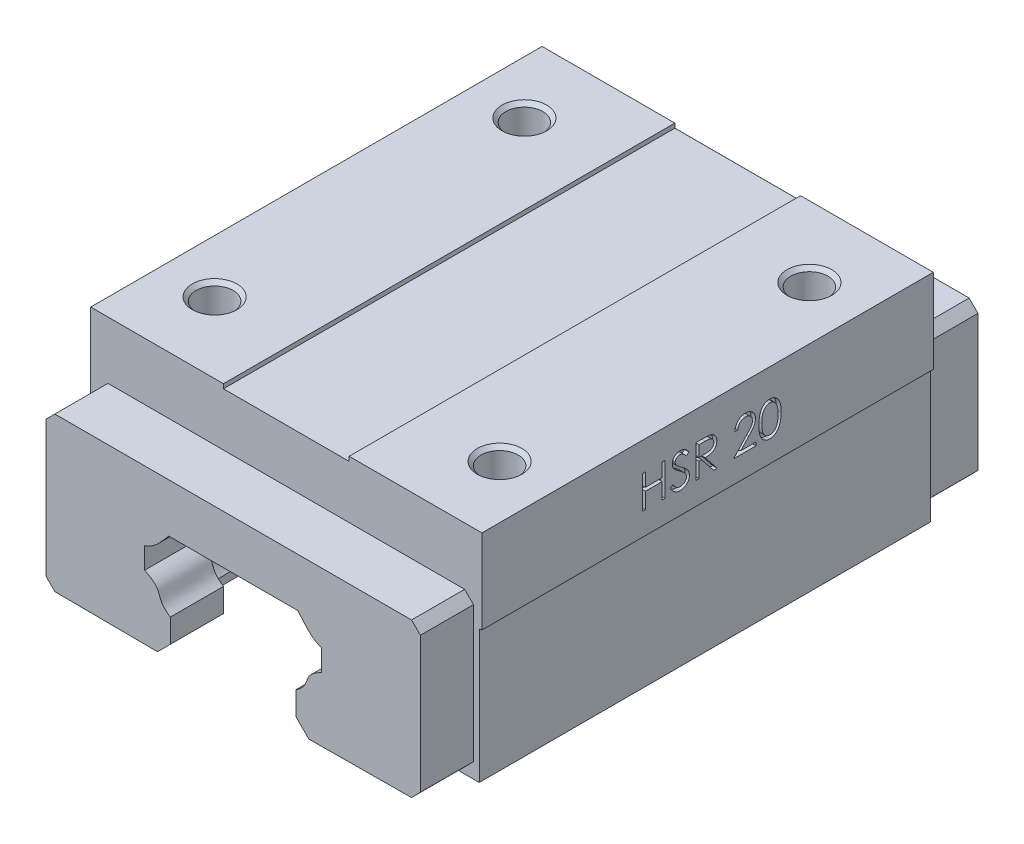
from build123d import *

# Parameters (mm, degrees)
BOSS_EXTRUDE1_DEPTH              = 51
BOSS_EXTRUDE3_DEPTH              = 6
CHAMFER1_SIZE                    = 1
CHAMFER1_EDGE_2_SIZE             = 1
CHAMFER1_EDGE_3_SIZE2            = 1.006844543
CHAMFER1_EDGE_3_SIZE             = 1
CHAMFER1_EDGE_4_SIZE2            = 1
CHAMFER1_EDGE_4_SIZE             = 1.006844543
CHAMFER1_OF_MIRROR4_SIZE         = 1
CHAMFER1_EDGE_2_OF_MIRROR4_SIZE  = 1
CHAMFER1_EDGE_3_OF_MIRROR4_SIZE2 = 1.006844543
CHAMFER1_EDGE_3_OF_MIRROR4_SIZE  = 1
CHAMFER1_EDGE_4_OF_MIRROR4_SIZE2 = 1
CHAMFER1_EDGE_4_OF_MIRROR4_SIZE  = 1.006844543
CUT_EXTRUDE1_DEPTH               = 0.5


with BuildPart() as part:
    # Sketch1 → Boss-Extrude1 (new body)
    with BuildSketch(Plane.XY):
        with BuildLine():
            Line((8.186769705, 11), (-8.186769705, 11))
            add(Edge.make_bspline(
                [(-8.186769705, 11), (-8.363836086, 10.799324769), (-8.709888403, 10.411068849), (-9.277449544, 9.75011771), (-9.7045178, 9.251154978), (-10.053828448, 8.908046415), (-10.269634561, 8.752888416), (-10.410763822, 8.68026119), (-10.489724529, 8.646859847), (-10.550742741, 8.625927759), (-10.57277649, 8.619058351), (-10.645173866, 8.597216578), (-10.745036898, 8.567019801), (-10.96378338, 8.500936701), (-11.38769033, 8.372834462), (-11.755697207, 8.261639185), (-12, 8.187818635)],
                knots=[-0.392908407, -0.392908407, -0.392908407, -0.392908407, -0.190329106, 0.012250195, 0.214829496, 0.417408798, 0.619988099, 0.721277749, 0.771922575, 0.8225674, 0.835228606, 0.847889813, 0.873212225, 0.923857051, 1.025146701, 1.227726002, 1.227726002, 1.227726002, 1.227726002], degree=3))
            Line((-12, 8.187818635), (-12, 2.939771986))
            add(Edge.make_bspline(
                [(-12, 2.939771986), (-11.765310399, 2.846514576), (-11.405654838, 2.703691145), (-11.012730745, 2.547344415), (-10.75009689, 2.443316846), (-10.629724696, 2.394119178), (-10.497141279, 2.327968435), (-10.336799963, 2.225917592), (-10.272656485, 2.169348301), (-10.226217691, 2.118184004)],
                knots=[-0.585104594, -0.585104594, -0.585104594, -0.585104594, -0.258530993, -0.095244192, -0.013600792, 0.068042608, 0.231329409, 0.39461621, 0.721189811, 0.721189811, 0.721189811, 0.721189811], degree=3))
            add(Edge.make_bspline(
                [(-10.226217691, 2.118184004), (-10.181586684, 1.988723576), (-10.098516815, 1.75729888), (-9.877516259, 1.266458818), (-9.562854794, 0.745877333), (-9.259202145, 0.381055923), (-9.1, 0.218184912)],
                knots=[0.146752228, 0.146752228, 0.146752228, 0.146752228, 0.298578938, 0.450405648, 0.602232359, 0.754059069, 0.754059069, 0.754059069, 0.754059069], degree=3))
            Line((-9.1, 0.218184912), (-9.1, -0.671572875))
            Line((-9.1, -0.671572875), (-12, -3.571572875))
            Line((-12, -3.571572875), (-21.8, -3.571572875))
            Line((-21.8, -3.571572875), (-21.8, 11.5))
            Line((-21.8, 11.5), (-22.1, 11.5))
            Line((-22.1, 11.5), (-22.1, 21))
            Line((-22.1, 21), (-7.1, 21))
            Line((-7.1, 21), (-7.1, 20.5))
            Line((-7.1, 20.5), (7.1, 20.5))
            Line((7.1, 20.5), (7.1, 21))
            Line((7.1, 21), (22.1, 21))
            Line((22.1, 21), (22.1, 11.5))
            Line((22.1, 11.5), (21.8, 11.5))
            Line((21.8, 11.5), (21.8, -3.571572875))
            Line((21.8, -3.571572875), (12, -3.571572875))
            Line((12, -3.571572875), (9.1, -0.671572875))
            Line((9.1, -0.671572875), (9.1, 0.218184912))
            add(Edge.make_bspline(
                [(9.1, 0.218184912), (9.259202145, 0.381055923), (9.562854794, 0.745877333), (9.877516259, 1.266458818), (10.098516815, 1.75729888), (10.181586684, 1.988723576), (10.226217691, 2.118184004)],
                knots=[0.146752228, 0.146752228, 0.146752228, 0.146752228, 0.298578938, 0.450405648, 0.602232359, 0.754059069, 0.754059069, 0.754059069, 0.754059069], degree=3))
            add(Edge.make_bspline(
                [(10.226217691, 2.118184004), (10.272656485, 2.169348301), (10.336799963, 2.225917592), (10.497141279, 2.327968435), (10.629724696, 2.394119178), (10.75009689, 2.443316846), (11.012730745, 2.547344415), (11.405654838, 2.703691145), (11.765310399, 2.846514576), (12, 2.939771986)],
                knots=[-0.585104594, -0.585104594, -0.585104594, -0.585104594, -0.258530993, -0.095244192, 0.068042608, 0.149686009, 0.231329409, 0.39461621, 0.721189811, 0.721189811, 0.721189811, 0.721189811], degree=3))
            Line((12, 2.939771986), (12, 8.187818635))
            add(Edge.make_bspline(
                [(12, 8.187818635), (11.755697207, 8.261639185), (11.38769033, 8.372834462), (10.96378338, 8.500936701), (10.745036898, 8.567019801), (10.645173866, 8.597216578), (10.57277649, 8.619058351), (10.550742741, 8.625927759), (10.489724529, 8.646859847), (10.410763822, 8.68026119), (10.269634561, 8.752888416), (10.053828448, 8.908046415), (9.7045178, 9.251154978), (9.277449544, 9.75011771), (8.709888403, 10.411068849), (8.363836086, 10.799324769), (8.186769705, 11)],
                knots=[-0.392908407, -0.392908407, -0.392908407, -0.392908407, -0.190329106, -0.089039455, -0.03839463, -0.013072217, -0.000411011, 0.012250195, 0.062895021, 0.113539846, 0.214829496, 0.417408798, 0.619988099, 0.8225674, 1.025146701, 1.227726002, 1.227726002, 1.227726002, 1.227726002], degree=3))
        make_face()
    extrude(amount=-BOSS_EXTRUDE1_DEPTH)

    # Sketch3 → M5 Tapped Hole1 (revolve, cut)
    with BuildSketch(Plane(origin=(-16.1, 21, -43), x_dir=(0, 0, 1), z_dir=(1, 0, 0))):
        Polygon((0, 0), (0, 9.2618073), (2.1, 8), (2.1, 0.425), (2.525, 0), align=None)
    m5_tapped_hole1 = revolve(axis=Axis((-16.1, 27.35, -43), (0, -1, 0)), mode=Mode.SUBTRACT)

    # Mirror1: M5 Tapped Hole1 across plane
    add(m5_tapped_hole1.mirror(Plane(origin=(0, 0, -25.5), x_dir=(1, 0, 0), z_dir=(0, 0, -1))), mode=Mode.SUBTRACT)

    # Mirror2: M5 Tapped Hole1 across plane
    add(m5_tapped_hole1.mirror(Plane.ZY), mode=Mode.SUBTRACT)

    # Mirror2 copy 1 sketch → Mirror2 copy 1 (revolve, cut)
    with BuildSketch(Plane(origin=(16.1, 21, -8), x_dir=(0, 0, -1), z_dir=(-1, 0, 0))):
        Polygon((0, 0), (0, 9.2618073), (2.1, 8), (2.1, 0.425), (2.525, 0), align=None)
    revolve(axis=Axis((16.1, 27.35, -8), (0, -1, 0)), mode=Mode.SUBTRACT)

    # Sketch5 → Boss-Extrude3 (add)
    with BuildSketch(Plane.XY):
        with BuildLine():
            Line((0, 14.507628115), (-21.14980175, 14.507628115))
            Line((-21.14980175, 14.507628115), (-21.14980175, -2.864633598))
            Line((-21.14980175, -2.864633598), (-8.55, -2.95))
            Line((-8.55, -2.95), (-7.1, -1.5))
            Line((-7.1, -1.5), (-7.1, 1.166788432))
            add(Edge.make_bspline(
                [(-10, 4.297156366), (-7.543055303, 3.07702891), (-9.018757763, 2.399897761), (-7.1, 1.166788432)],
                knots=[0, 0, 0, 0, 1, 1, 1, 1], degree=3))
            Line((-10, 4.297156366), (-10, 6.702843634))
            add(Edge.make_bspline(
                [(-10, 6.702843634), (-9.580341538, 6.835205115), (-9.158563098, 7.065013576), (-8.245096857, 7.844206232), (-7.926045594, 8.275331007), (-7.284232282, 9)],
                knots=[0, 0, 0, 0, 0.378200465, 0.478200465, 1, 1, 1, 1], degree=3))
            Line((-7.284232282, 9), (7.284232282, 9))
            add(Edge.make_bspline(
                [(10, 6.702843634), (9.580341538, 6.835205115), (9.158563098, 7.065013576), (8.245096857, 7.844206232), (7.926045594, 8.275331007), (7.284232282, 9)],
                knots=[0, 0, 0, 0, 0.378200465, 0.478200465, 1, 1, 1, 1], degree=3))
            Line((10, 6.702843634), (10, 4.297156366))
            add(Edge.make_bspline(
                [(10, 4.297156366), (7.543055303, 3.07702891), (9.018757763, 2.399897761), (7.1, 1.166788432)],
                knots=[0, 0, 0, 0, 1, 1, 1, 1], degree=3))
            Line((7.1, 1.166788432), (7.1, -1.5))
            Line((7.1, -1.5), (8.55, -2.95))
            Line((8.55, -2.95), (21.14980175, -2.864633598))
            Line((21.14980175, -2.864633598), (21.14980175, 14.507628115))
            Line((21.14980175, 14.507628115), (0, 14.507628115))
        make_face()
    boss_extrude3 = extrude(amount=BOSS_EXTRUDE3_DEPTH)

    # Chamfer1
    chamfer1_edges = [part.edges().sort_by_distance(p)[0] for p in [
        (21.14980175, 14.507628115, 3),
    ]]
    chamfer(chamfer1_edges, length=CHAMFER1_SIZE)

    # Chamfer1 edge 2
    chamfer1_edge_2_edges = [part.edges().sort_by_distance(p)[0] for p in [
        (-21.14980175, 14.507628115, 3),
    ]]
    chamfer(chamfer1_edge_2_edges, length=CHAMFER1_EDGE_2_SIZE)

    # Chamfer1 edge 3
    chamfer1_edge_3_edges = [part.edges().sort_by_distance(p)[0] for p in [
        (-21.14980175, -2.864633598, 3),
    ]]
    chamfer(chamfer1_edge_3_edges, length=CHAMFER1_EDGE_3_SIZE, length2=CHAMFER1_EDGE_3_SIZE2)

    # Chamfer1 edge 4
    chamfer1_edge_4_edges = [part.edges().sort_by_distance(p)[0] for p in [
        (21.14980175, -2.864633598, 3),
    ]]
    chamfer(chamfer1_edge_4_edges, length=CHAMFER1_EDGE_4_SIZE, length2=CHAMFER1_EDGE_4_SIZE2)

    # Mirror4: Boss-Extrude3 across plane
    add(boss_extrude3.mirror(Plane(origin=(0, 0, -25.5), x_dir=(1, 0, 0), z_dir=(0, 0, -1))))

    # Chamfer1 of Mirror4
    chamfer1_of_mirror4_edges = [part.edges().sort_by_distance(p)[0] for p in [
        (21.14980175, 14.507628115, -54),
    ]]
    chamfer(chamfer1_of_mirror4_edges, length=CHAMFER1_OF_MIRROR4_SIZE)

    # Chamfer1 edge 2 of Mirror4
    chamfer1_edge_2_of_mirror4_edges = [part.edges().sort_by_distance(p)[0] for p in [
        (-21.14980175, 14.507628115, -54),
    ]]
    chamfer(chamfer1_edge_2_of_mirror4_edges, length=CHAMFER1_EDGE_2_OF_MIRROR4_SIZE)

    # Chamfer1 edge 3 of Mirror4
    chamfer1_edge_3_of_mirror4_edges = [part.edges().sort_by_distance(p)[0] for p in [
        (-21.14980175, -2.864633598, -54),
    ]]
    chamfer(chamfer1_edge_3_of_mirror4_edges, length=CHAMFER1_EDGE_3_OF_MIRROR4_SIZE, length2=CHAMFER1_EDGE_3_OF_MIRROR4_SIZE2)

    # Chamfer1 edge 4 of Mirror4
    chamfer1_edge_4_of_mirror4_edges = [part.edges().sort_by_distance(p)[0] for p in [
        (21.14980175, -2.864633598, -54),
    ]]
    chamfer(chamfer1_edge_4_of_mirror4_edges, length=CHAMFER1_EDGE_4_OF_MIRROR4_SIZE, length2=CHAMFER1_EDGE_4_OF_MIRROR4_SIZE2)

    # Sketch6 → Cut-Extrude1 (cut)
    with BuildSketch(Plane(origin=(22.1, 0, 0), x_dir=(0, 0, -1), z_dir=(1, 0, 0))):
        Polygon((18.134408835, 17.740985443), (18.466834048, 17.740985443), (18.466834048, 16.221327324), (20.366406698, 16.221327324), (20.366406698, 17.740985443), (20.698831912, 17.740985443), (20.698831912, 14.036818777), (20.366406698, 14.036818777), (20.366406698, 15.841412794), (18.466834048, 15.841412794), (18.466834048, 14.036818777), (18.134408835, 14.036818777), align=None)
        with BuildLine():
            Line((21.268703706, 14.751384582), (21.581836385, 14.939115785))
            add(Edge.make_bspline(
                [(21.581836385, 14.939115785), (21.610959853, 14.890364311), (21.666759294, 14.796958368), (21.759841149, 14.670743609), (21.856290146, 14.56346866), (21.956820524, 14.475757583), (22.060818653, 14.406702511), (22.168963443, 14.35780515), (22.280890459, 14.327308242), (22.357062754, 14.323603984), (22.395090926, 14.321754674)],
                knots=[0, 0, 0, 0, 0.000170287, 0.000326263, 0.000469665, 0.000602223, 0.000725501, 0.000842734, 0.000957019, 0.001070958, 0.001070958, 0.001070958, 0.001070958], degree=3))
            add(Edge.make_bspline(
                [(22.395090926, 14.321754674), (22.427567853, 14.322659203), (22.491953438, 14.324452432), (22.586740145, 14.341682948), (22.678795886, 14.368154118), (22.766223361, 14.406064603), (22.84781622, 14.451931167), (22.919366639, 14.507330872), (22.981222109, 14.569355773), (23.031820088, 14.638552416), (23.070639792, 14.712971398), (23.100476398, 14.789357613), (23.117034101, 14.868911015), (23.119528332, 14.922473755), (23.12078704, 14.949504073)],
                knots=[0, 0, 0, 0, 9.7343e-05, 0.000192983, 0.000288081, 0.000384149, 0.00047821, 0.000568151, 0.000654726, 0.000740213, 0.000824192, 0.000905916, 0.00098552, 0.001066618, 0.001066618, 0.001066618, 0.001066618], degree=3))
            add(Edge.make_bspline(
                [(23.12078704, 14.949504073), (23.119226728, 14.980344806), (23.116054841, 15.043039508), (23.089245691, 15.135537475), (23.047071905, 15.227075444), (23.008164774, 15.283697617), (22.987965358, 15.313094151)],
                knots=[0, 0, 0, 0, 9.2372e-05, 0.000187779, 0.000286712, 0.000393535, 0.000393535, 0.000393535, 0.000393535], degree=3))
            add(Edge.make_bspline(
                [(22.987965358, 15.313094151), (22.971380625, 15.334310372), (22.936563052, 15.378851176), (22.876706351, 15.445150717), (22.80646888, 15.513538543), (22.728254285, 15.586626045), (22.639213432, 15.661013963), (22.542135146, 15.740249558), (22.434540895, 15.82131956), (22.359082261, 15.875688859), (22.320146849, 15.903742521)],
                knots=[0, 0, 0, 0, 8.0771e-05, 0.000169569, 0.000267687, 0.000374806, 0.000490623, 0.000615664, 0.000750713, 0.000894683, 0.000894683, 0.000894683, 0.000894683], degree=3))
            add(Edge.make_bspline(
                [(22.320146849, 15.903742521), (22.281174786, 15.93150111), (22.20666317, 15.984573417), (22.102461171, 16.063339118), (22.009280781, 16.135352213), (21.927536155, 16.201290626), (21.857263248, 16.261163299), (21.797908305, 16.314395285), (21.750983332, 16.36242622), (21.724889509, 16.393584974), (21.713174026, 16.407574486)],
                knots=[0, 0, 0, 0, 0.000143534, 0.000274427, 0.00039183, 0.000496823, 0.00058946, 0.000668773, 0.000735941, 0.00079067, 0.00079067, 0.00079067, 0.00079067], degree=3))
            add(Edge.make_bspline(
                [(21.713174026, 16.407574486), (21.696798915, 16.42937725), (21.664595063, 16.472255311), (21.622086041, 16.539274119), (21.585955427, 16.607878742), (21.557631959, 16.678253532), (21.533781127, 16.749410498), (21.517738984, 16.822278066), (21.507693922, 16.896529271), (21.506665236, 16.946496892), (21.506150288, 16.971510116)],
                knots=[0, 0, 0, 0, 8.1777e-05, 0.000160826, 0.000237825, 0.000314026, 0.000388176, 0.000462703, 0.00053753, 0.000612533, 0.000612533, 0.000612533, 0.000612533], degree=3))
            add(Edge.make_bspline(
                [(21.506150288, 16.971510116), (21.507531634, 17.010699961), (21.510264801, 17.088241995), (21.533379348, 17.201516291), (21.569863161, 17.309663582), (21.62097525, 17.411613185), (21.686864282, 17.504710515), (21.763112939, 17.590026456), (21.853930095, 17.661748205), (21.953574954, 17.7244143), (22.062642948, 17.773463738), (22.176933321, 17.810464108), (22.296627722, 17.831428906), (22.377699373, 17.834437499), (22.418835584, 17.835964076)],
                knots=[0, 0, 0, 0, 0.000117474, 0.000232437, 0.000345304, 0.000459127, 0.000573166, 0.00068662, 0.000801115, 0.000919096, 0.001038969, 0.001158885, 0.001278682, 0.00140208, 0.00140208, 0.00140208, 0.00140208], degree=3))
            add(Edge.make_bspline(
                [(22.418835584, 17.835964076), (22.46248559, 17.834458542), (22.549291521, 17.831464516), (22.676978607, 17.805432129), (22.799915366, 17.762357251), (22.898809488, 17.713474255), (22.976208327, 17.66465184), (23.035234469, 17.620180859), (23.095048771, 17.568983869), (23.156133712, 17.5109245), (23.217454243, 17.445470022), (23.27992073, 17.37306871), (23.343679248, 17.294163021), (23.384695867, 17.237833758), (23.405722937, 17.208956697)],
                knots=[0, 0, 0, 0, 0.00013085, 0.00026022, 0.000389052, 0.000520793, 0.000590167, 0.000663331, 0.000742285, 0.000826262, 0.000916021, 0.001011235, 0.001113097, 0.001220246, 0.001220246, 0.001220246, 0.001220246], degree=3))
            Line((23.405722937, 17.208956697), (23.105204608, 16.981156384))
            add(Edge.make_bspline(
                [(23.105204608, 16.981156384), (23.087058496, 17.004533581), (23.052113327, 17.049552597), (22.99905962, 17.112598906), (22.949054801, 17.17018968), (22.899788962, 17.220211941), (22.853864035, 17.265405032), (22.809290165, 17.304097441), (22.76670881, 17.33666828), (22.713033413, 17.371427714), (22.645598828, 17.405883347), (22.560948527, 17.435039455), (22.472486386, 17.452560229), (22.412235859, 17.454876801), (22.381734556, 17.456049546)],
                knots=[0, 0, 0, 0, 8.877e-05, 0.00017095, 0.000247176, 0.000317492, 0.000381513, 0.000440428, 0.000494448, 0.000542197, 0.000632129, 0.00072083, 0.000810036, 0.000901498, 0.000901498, 0.000901498, 0.000901498], degree=3))
            add(Edge.make_bspline(
                [(22.381734556, 17.456049546), (22.343468903, 17.454767163), (22.269677196, 17.45229421), (22.16491253, 17.425285559), (22.070621459, 17.382759756), (21.989603328, 17.323159738), (21.92214836, 17.252546687), (21.873353416, 17.171289066), (21.843984492, 17.081561023), (21.84040068, 17.018969437), (21.838575501, 16.987092548)],
                knots=[0, 0, 0, 0, 0.000114562, 0.000220923, 0.000322189, 0.000423114, 0.000520757, 0.000613272, 0.000705259, 0.000800726, 0.000800726, 0.000800726, 0.000800726], degree=3))
            add(Edge.make_bspline(
                [(21.838575501, 16.987092548), (21.83899156, 16.967247233), (21.839824359, 16.927524153), (21.851439353, 16.868838064), (21.866361143, 16.81030023), (21.890007095, 16.75217383), (21.922651708, 16.6934423), (21.965519686, 16.633094295), (22.019508774, 16.570597903), (22.060865279, 16.529950099), (22.082700268, 16.508489283)],
                knots=[0, 0, 0, 0, 5.9436e-05, 0.000118969, 0.000178907, 0.0002405, 0.000306589, 0.000380083, 0.000462176, 0.000553998, 0.000553998, 0.000553998, 0.000553998], degree=3))
            add(Edge.make_bspline(
                [(22.082700268, 16.508489283), (22.090808553, 16.501253431), (22.110071985, 16.484062702), (22.145289006, 16.455919205), (22.191795134, 16.421202937), (22.248375964, 16.378248027), (22.316074755, 16.328420147), (22.394898952, 16.272356407), (22.483969907, 16.208236796), (22.547175602, 16.163408399), (22.580596068, 16.139705061)],
                knots=[0, 0, 0, 0, 3.2598e-05, 7.7446e-05, 0.000135176, 0.000206707, 0.000290559, 0.00038734, 0.000496888, 0.000619806, 0.000619806, 0.000619806, 0.000619806], degree=3))
            add(Edge.make_bspline(
                [(22.580596068, 16.139705061), (22.620797826, 16.110451289), (22.698642959, 16.053805414), (22.809405564, 15.968698819), (22.909834844, 15.885463264), (23.000283402, 15.804630297), (23.081644796, 15.726813065), (23.153016384, 15.651075366), (23.215125396, 15.577959801), (23.281990069, 15.484220492), (23.350313761, 15.369093844), (23.408989356, 15.228041042), (23.445986941, 15.086439936), (23.450825128, 14.991267368), (23.453212253, 14.944309929)],
                knots=[0, 0, 0, 0, 0.000149154, 0.000288815, 0.000418974, 0.000540368, 0.000652671, 0.000756607, 0.000852468, 0.000940193, 0.001101818, 0.001252848, 0.001397361, 0.001538104, 0.001538104, 0.001538104, 0.001538104], degree=3))
            add(Edge.make_bspline(
                [(23.453212253, 14.944309929), (23.452516782, 14.911101159), (23.451139346, 14.845328512), (23.435305712, 14.748750222), (23.412107399, 14.654949218), (23.377142994, 14.565084958), (23.334467651, 14.477513417), (23.280316705, 14.394531723), (23.217549406, 14.314303284), (23.145547005, 14.238967422), (23.066758425, 14.169809365), (22.983484848, 14.108289442), (22.895589976, 14.056993799), (22.803550624, 14.015135825), (22.707345651, 13.982397852), (22.607007413, 13.958677566), (22.502370513, 13.944119438), (22.431250004, 13.942608391), (22.395090926, 13.941840144)],
                knots=[0, 0, 0, 0, 9.953e-05, 0.000197128, 0.000292872, 0.000388925, 0.000485824, 0.000584621, 0.00068556, 0.000791055, 0.000896738, 0.000999737, 0.001101166, 0.001201449, 0.001302584, 0.001405533, 0.001510368, 0.001618795, 0.001618795, 0.001618795, 0.001618795], degree=3))
            add(Edge.make_bspline(
                [(22.395090926, 13.941840144), (22.367113521, 13.942381145), (22.311511059, 13.943456332), (22.229268524, 13.952961521), (22.148687458, 13.966409872), (22.07077901, 13.987760763), (21.994539416, 14.013665564), (21.920300259, 14.045561966), (21.848025561, 14.083786004), (21.777310286, 14.127489905), (21.708334284, 14.178351018), (21.641744514, 14.237589635), (21.575356126, 14.303571961), (21.511128631, 14.378089807), (21.447762887, 14.459939278), (21.386508237, 14.549886164), (21.326096752, 14.64744053), (21.288192049, 14.716089413), (21.268703706, 14.751384582)],
                knots=[0, 0, 0, 0, 8.3901e-05, 0.000166745, 0.000248114, 0.000328749, 0.000408767, 0.000489538, 0.000570856, 0.000653836, 0.000738726, 0.000827585, 0.00092098, 0.001019333, 0.001122485, 0.001231362, 0.001345648, 0.001466586, 0.001466586, 0.001466586, 0.001466586], degree=3))
        make_face()
        with BuildLine():
            Line((24.213041313, 17.740985443), (24.954319859, 17.740985443))
            add(Edge.make_bspline(
                [(24.954319859, 17.740985443), (25.003787553, 17.740820782), (25.098771006, 17.740504613), (25.234844384, 17.73874168), (25.358486395, 17.73368882), (25.469632392, 17.72934057), (25.568280335, 17.721411598), (25.654732717, 17.713833247), (25.728591364, 17.703912789), (25.773301557, 17.69469955), (25.793545119, 17.690528045)],
                knots=[0, 0, 0, 0, 0.000148406, 0.000284956, 0.000408212, 0.000519636, 0.000618603, 0.000705064, 0.000779989, 0.000841983, 0.000841983, 0.000841983, 0.000841983], degree=3))
            add(Edge.make_bspline(
                [(25.793545119, 17.690528045), (25.820645463, 17.683832218), (25.874268027, 17.670583405), (25.951473514, 17.642580327), (26.02504284, 17.610174558), (26.094670404, 17.572112954), (26.16000745, 17.528112979), (26.221727662, 17.478934216), (26.280111111, 17.424845757), (26.332796669, 17.364483883), (26.382473832, 17.30115691), (26.424371795, 17.232678767), (26.460488986, 17.161070317), (26.48924445, 17.0856033), (26.512398639, 17.007009592), (26.528724742, 16.924577282), (26.538515582, 16.838681916), (26.53951238, 16.780094796), (26.540017809, 16.750387987)],
                knots=[0, 0, 0, 0, 8.3694e-05, 0.000165602, 0.000245991, 0.000324694, 0.00040331, 0.000481995, 0.000561267, 0.000641683, 0.000722123, 0.000802429, 0.000882071, 0.000962408, 0.001044357, 0.001127596, 0.001214209, 0.001303301, 0.001303301, 0.001303301, 0.001303301], degree=3))
            add(Edge.make_bspline(
                [(26.540017809, 16.750387987), (26.538463119, 16.701032502), (26.535429517, 16.604727166), (26.507145449, 16.464962733), (26.460815299, 16.334587375), (26.396973152, 16.21376525), (26.31567254, 16.104851483), (26.217962136, 16.009188252), (26.10378743, 15.929136011), (25.997499738, 15.873623459), (25.903610543, 15.838070964), (25.826316954, 15.813055818), (25.742002736, 15.793728571), (25.651475723, 15.776414098), (25.554359188, 15.763341888), (25.450885896, 15.753767576), (25.340982052, 15.747783708), (25.265481537, 15.746892586), (25.226641407, 15.746434161)],
                knots=[0, 0, 0, 0, 0.00014793, 0.00028865, 0.000425713, 0.000561809, 0.000697005, 0.000831859, 0.000970218, 0.001113919, 0.001190261, 0.001271223, 0.001357431, 0.001449552, 0.00154767, 0.001651261, 0.001761241, 0.001877759, 0.001877759, 0.001877759, 0.001877759], degree=3))
            Line((25.226641407, 15.746434161), (26.587507125, 14.036818777))
            Line((26.587507125, 14.036818777), (26.176427732, 14.036818777))
            Line((26.176427732, 14.036818777), (24.815562013, 15.746434161))
            Line((24.815562013, 15.746434161), (24.545466527, 15.746434161))
            Line((24.545466527, 15.746434161), (24.545466527, 14.036818777))
            Line((24.545466527, 14.036818777), (24.213041313, 14.036818777))
            Line((24.213041313, 14.036818777), (24.213041313, 17.740985443))
        make_face()
        with BuildLine():
            Line((24.545466527, 17.361070913), (24.545466527, 16.126348691))
            Line((24.545466527, 16.126348691), (25.223673325, 16.121154547))
            add(Edge.make_bspline(
                [(25.223673325, 16.121154547), (25.255338699, 16.121140538), (25.316715214, 16.121113385), (25.405510084, 16.125340132), (25.488187202, 16.130148477), (25.564430332, 16.137503201), (25.634273532, 16.14698171), (25.697681894, 16.158838202), (25.754758924, 16.172651635), (25.821326544, 16.194031689), (25.895660207, 16.227904725), (25.976444335, 16.277186544), (26.045238476, 16.339172196), (26.10335988, 16.410052437), (26.150063528, 16.487984133), (26.182990452, 16.572033124), (26.203884537, 16.660077565), (26.206348914, 16.720591063), (26.207592595, 16.751130008)],
                knots=[0, 0, 0, 0, 9.4982e-05, 0.000184101, 0.000266629, 0.000343417, 0.00041383, 0.00047801, 0.000536859, 0.000589892, 0.000687534, 0.000781211, 0.000872658, 0.000963866, 0.001055363, 0.001143962, 0.001233784, 0.001325296, 0.001325296, 0.001325296, 0.001325296], degree=3))
            add(Edge.make_bspline(
                [(26.207592595, 16.751130008), (26.206320351, 16.780918465), (26.203799226, 16.839948318), (26.183215946, 16.92636749), (26.148408017, 17.007930012), (26.101500315, 17.084304092), (26.044351209, 17.153630995), (25.977339858, 17.212947566), (25.902298526, 17.261894916), (25.832161508, 17.293173302), (25.769471966, 17.312350147), (25.715042243, 17.325845128), (25.653540929, 17.336687191), (25.584669402, 17.345374056), (25.508721676, 17.352840538), (25.425313737, 17.357869504), (25.334998978, 17.36084751), (25.272401809, 17.360994713), (25.239997777, 17.361070913)],
                knots=[0, 0, 0, 0, 8.9293e-05, 0.000176945, 0.000264733, 0.000354324, 0.00044496, 0.000533263, 0.000621763, 0.000712775, 0.000762529, 0.000818319, 0.000880904, 0.000949749, 0.001026536, 0.001109805, 0.00120038, 0.001297587, 0.001297587, 0.001297587, 0.001297587], degree=3))
            Line((25.239997777, 17.361070913), (24.545466527, 17.361070913))
        make_face(mode=Mode.SUBTRACT)
        with BuildLine():
            Line((28.914483621, 16.601241854), (28.582058407, 16.601241854))
            add(Edge.make_bspline(
                [(28.582058407, 16.601241854), (28.584224978, 16.645343543), (28.588480064, 16.731958088), (28.60840667, 16.858242555), (28.636919098, 16.978950551), (28.677232554, 17.093112876), (28.727298365, 17.201738947), (28.787337644, 17.304397297), (28.858451135, 17.400696305), (28.939103262, 17.489743248), (29.026700072, 17.571433427), (29.121215525, 17.641976892), (29.220534845, 17.701579761), (29.324356709, 17.751407409), (29.433852472, 17.788808746), (29.548028497, 17.816559981), (29.667386416, 17.833256613), (29.748708773, 17.83505132), (29.790067889, 17.835964076)],
                knots=[0, 0, 0, 0, 0.000132379, 0.00025999, 0.00038291, 0.000504003, 0.000622526, 0.000741261, 0.000860138, 0.00098098, 0.001101226, 0.001218911, 0.001334077, 0.001448254, 0.001563709, 0.001680511, 0.001800351, 0.001924378, 0.001924378, 0.001924378, 0.001924378], degree=3))
            add(Edge.make_bspline(
                [(29.790067889, 17.835964076), (29.830684684, 17.835013209), (29.910495236, 17.833144791), (30.026977534, 17.817099368), (30.137866838, 17.791968617), (30.242946391, 17.756709802), (30.341377809, 17.709312949), (30.433900531, 17.652377221), (30.521616056, 17.586527899), (30.600574902, 17.509000947), (30.673079286, 17.426236756), (30.735629172, 17.337878725), (30.78919477, 17.246619398), (30.833843398, 17.151762884), (30.866711145, 17.052416046), (30.891664749, 16.950025256), (30.905769595, 16.843530665), (30.907934335, 16.771451227), (30.909034903, 16.734805556)],
                knots=[0, 0, 0, 0, 0.000121802, 0.000239337, 0.000352017, 0.000462538, 0.000571068, 0.000678986, 0.000788065, 0.000899319, 0.001010307, 0.001117785, 0.001223541, 0.00132745, 0.001431635, 0.001536921, 0.001643226, 0.001753168, 0.001753168, 0.001753168, 0.001753168], degree=3))
            add(Edge.make_bspline(
                [(30.909034903, 16.734805556), (30.907242867, 16.683214097), (30.903690241, 16.580936538), (30.873300859, 16.430637475), (30.825838302, 16.285017773), (30.768691099, 16.167820795), (30.711041096, 16.073382014), (30.65909015, 15.995627635), (30.598273225, 15.911907681), (30.527705148, 15.822502498), (30.448845692, 15.726711791), (30.360980569, 15.624593424), (30.263483217, 15.517202467), (30.195052971, 15.443854039), (30.159594131, 15.405846721)],
                knots=[0, 0, 0, 0, 0.000154641, 0.000306569, 0.000458152, 0.000613135, 0.00069636, 0.000789999, 0.000893598, 0.001006707, 0.001131642, 0.001265808, 0.001410808, 0.001566748, 0.001566748, 0.001566748, 0.001566748], degree=3))
            Line((30.159594131, 15.405846721), (29.232810444, 14.416733307))
            Line((29.232810444, 14.416733307), (30.956524219, 14.416733307))
            Line((30.956524219, 14.416733307), (30.956524219, 14.036818777))
            Line((30.956524219, 14.036818777), (28.439590459, 14.036818777))
            Line((28.439590459, 14.036818777), (29.876142275, 15.569833267))
            add(Edge.make_bspline(
                [(29.876142275, 15.569833267), (29.911117955, 15.606343974), (29.978299079, 15.676473572), (30.073318973, 15.778859871), (30.158661902, 15.873844802), (30.234880309, 15.961248899), (30.300320769, 16.042350642), (30.358393881, 16.11452337), (30.404924132, 16.180938496), (30.455422925, 16.257922313), (30.504332722, 16.351915348), (30.546361633, 16.466780169), (30.571989014, 16.585024845), (30.575063298, 16.664931168), (30.576609689, 16.705124733)],
                knots=[0, 0, 0, 0, 0.000151679, 0.000291345, 0.000419026, 0.000534762, 0.000639179, 0.000731658, 0.000812569, 0.000882343, 0.001007795, 0.001129387, 0.001248429, 0.001368914, 0.001368914, 0.001368914, 0.001368914], degree=3))
            add(Edge.make_bspline(
                [(30.576609689, 16.705124733), (30.575936862, 16.730399213), (30.574610849, 16.78021036), (30.562908119, 16.853241454), (30.545222833, 16.923689216), (30.519880769, 16.991770338), (30.486430302, 17.056800319), (30.445712642, 17.118858319), (30.398733158, 17.178854141), (30.344386398, 17.235108048), (30.284684206, 17.28662899), (30.221613625, 17.332268647), (30.154885598, 17.37041004), (30.084781469, 17.401676908), (30.01149668, 17.426204186), (29.934889492, 17.443199516), (29.855171575, 17.453870145), (29.800737792, 17.455313893), (29.773001416, 17.456049546)],
                knots=[0, 0, 0, 0, 7.5777e-05, 0.000149342, 0.000221329, 0.000293412, 0.000366752, 0.000440227, 0.000515786, 0.00059503, 0.000674467, 0.0007521, 0.000828214, 0.00090461, 0.000982043, 0.00105963, 0.001139703, 0.001222892, 0.001222892, 0.001222892, 0.001222892], degree=3))
            add(Edge.make_bspline(
                [(29.773001416, 17.456049546), (29.744033951, 17.455292803), (29.687146634, 17.453806686), (29.603623991, 17.443411033), (29.523946543, 17.425476686), (29.447913862, 17.400948039), (29.3753973, 17.369771074), (29.306749521, 17.330938978), (29.242124629, 17.284601448), (29.181401142, 17.232065192), (29.125453431, 17.173573648), (29.076297154, 17.10836977), (29.033345739, 17.037644089), (28.995870967, 16.96158744), (28.965437862, 16.879509689), (28.942182944, 16.791702201), (28.923781865, 16.698546239), (28.917634514, 16.634215358), (28.914483621, 16.601241854)],
                knots=[0, 0, 0, 0, 8.6896e-05, 0.000170649, 0.000252018, 0.000331566, 0.00041, 0.000488415, 0.000567687, 0.000648171, 0.000729, 0.00081003, 0.000892621, 0.000976912, 0.001064019, 0.00115474, 0.001249187, 0.001348502, 0.001348502, 0.001348502, 0.001348502], degree=3))
        make_face()
        with BuildLine():
            add(Edge.make_bspline(
                [(31.288949433, 15.887418069), (31.289296586, 15.946787804), (31.289970934, 16.062114371), (31.297472847, 16.23016145), (31.309935084, 16.38781109), (31.327013803, 16.535070835), (31.347797332, 16.671978702), (31.375542056, 16.79816882), (31.407093939, 16.914225237), (31.443661944, 17.020526405), (31.48492402, 17.118504474), (31.529833613, 17.209971145), (31.58017302, 17.294788024), (31.633065253, 17.374308852), (31.690651362, 17.447231929), (31.751292582, 17.51458708), (31.817355735, 17.574817624), (31.886595085, 17.629688294), (31.95963751, 17.677788985), (32.034400998, 17.720156967), (32.111400152, 17.756351826), (32.190845196, 17.784810871), (32.272022069, 17.808317351), (32.355214548, 17.82439232), (32.440559992, 17.834506715), (32.498166594, 17.83547368), (32.527381758, 17.835964076)],
                knots=[0, 0, 0, 0, 0.000178099, 0.00034596, 0.000504513, 0.000652421, 0.000790638, 0.000919734, 0.001039806, 0.00115127, 0.001256695, 0.001358571, 0.001456689, 0.001552386, 0.001644865, 0.001735209, 0.001823957, 0.001912727, 0.001999987, 0.002086042, 0.002170362, 0.002254867, 0.002338955, 0.002423649, 0.002508788, 0.002596397, 0.002596397, 0.002596397, 0.002596397], degree=3))
            add(Edge.make_bspline(
                [(32.527381758, 17.835964076), (32.556840973, 17.835447805), (32.615426082, 17.834421104), (32.702040479, 17.824553265), (32.786653892, 17.80817966), (32.868905589, 17.784979962), (32.9494712, 17.75619787), (33.027720565, 17.720122338), (33.104139726, 17.67812887), (33.17751428, 17.628785267), (33.248649748, 17.573770691), (33.315798842, 17.5115802), (33.378967675, 17.442841747), (33.43894904, 17.368290774), (33.494041214, 17.286497393), (33.546506429, 17.19888421), (33.593466834, 17.103919045), (33.638694365, 17.003186383), (33.677733093, 16.893899011), (33.712939869, 16.776672973), (33.741386778, 16.650123625), (33.765082091, 16.514914932), (33.783438772, 16.370550345), (33.796808319, 16.217339328), (33.803870667, 16.055181081), (33.805200676, 15.944312358), (33.805883194, 15.887418069)],
                knots=[0, 0, 0, 0, 8.835e-05, 0.000175701, 0.000261124, 0.00034664, 0.000431843, 0.00051751, 0.000604861, 0.000693149, 0.000782503, 0.000874397, 0.000967339, 0.001062364, 0.001161153, 0.001262959, 0.001368485, 0.001478784, 0.001594037, 0.001716353, 0.001845773, 0.001982893, 0.002128035, 0.002282213, 0.002444144, 0.002614834, 0.002614834, 0.002614834, 0.002614834], degree=3))
            add(Edge.make_bspline(
                [(33.805883194, 15.887418069), (33.8051936, 15.830771933), (33.803849955, 15.720399247), (33.79688749, 15.558970632), (33.783172939, 15.406572703), (33.766017368, 15.262839963), (33.742256765, 15.12837065), (33.713041298, 15.002699442), (33.68060304, 14.885283633), (33.640561216, 14.777085124), (33.596734881, 14.67659455), (33.549051465, 14.582755152), (33.497965899, 14.494737492), (33.442309477, 14.413246093), (33.382986281, 14.337703681), (33.318726622, 14.269443697), (33.251341919, 14.206821403), (33.179997112, 14.15109843), (33.105478221, 14.102325345), (33.029321531, 14.058707354), (32.950175783, 14.023536085), (32.869834575, 13.9933365), (32.787148721, 13.970264355), (32.702221291, 13.954311191), (32.615484274, 13.943122651), (32.556850951, 13.942269127), (32.527381758, 13.941840144)],
                knots=[0, 0, 0, 0, 0.000169949, 0.000331138, 0.000484577, 0.00062889, 0.000765278, 0.000893975, 0.001015877, 0.001130432, 0.001239754, 0.001344618, 0.001446047, 0.001544836, 0.001640441, 0.001733889, 0.001825783, 0.001916178, 0.002005085, 0.002092797, 0.00217914, 0.002264598, 0.002350114, 0.002436265, 0.002523701, 0.002612051, 0.002612051, 0.002612051, 0.002612051], degree=3))
            add(Edge.make_bspline(
                [(32.527381758, 13.941840144), (32.498167404, 13.942333704), (32.4405624, 13.943306907), (32.35520525, 13.953375606), (32.272356331, 13.969563347), (32.191606816, 13.992229253), (32.112542421, 14.019973288), (32.036240518, 14.05611927), (31.961852719, 14.097747826), (31.889577489, 14.145156314), (31.820772952, 14.199471762), (31.755051928, 14.259547301), (31.694065449, 14.326882078), (31.637302698, 14.40041288), (31.583355121, 14.479463228), (31.533730535, 14.565112422), (31.487829714, 14.657020852), (31.445873686, 14.755782307), (31.408674684, 14.862837939), (31.37581586, 14.979412487), (31.34987171, 15.106534868), (31.327664749, 15.243184082), (31.30975311, 15.389947325), (31.297524782, 15.546904273), (31.289966891, 15.713957119), (31.289294775, 15.828542631), (31.288949433, 15.887418069)],
                knots=[0, 0, 0, 0, 8.7609e-05, 0.000172747, 0.000257442, 0.000340614, 0.00042417, 0.00050849, 0.000593534, 0.000679765, 0.000767493, 0.000856242, 0.000946586, 0.001039649, 0.001134732, 0.001233491, 0.001336362, 0.001442758, 0.001555166, 0.001676152, 0.001805819, 0.001944153, 0.002091412, 0.002249226, 0.002416345, 0.00259296, 0.00259296, 0.00259296, 0.00259296], degree=3))
        make_face()
        with BuildLine():
            add(Edge.make_bspline(
                [(31.621374647, 15.88890211), (31.621501061, 15.839426404), (31.621746408, 15.743403773), (31.628155887, 15.603869655), (31.636887382, 15.473726057), (31.648149422, 15.352807731), (31.664874209, 15.241523968), (31.683613893, 15.139109387), (31.706418954, 15.046105977), (31.733401182, 14.961875544), (31.764134226, 14.884988614), (31.797689598, 14.813443994), (31.833737197, 14.746396528), (31.874079964, 14.684448459), (31.918016739, 14.627397769), (31.964555105, 14.574234688), (32.015431924, 14.526824549), (32.085815051, 14.469963628), (32.178732987, 14.411205878), (32.295806302, 14.3600396), (32.416105412, 14.327884833), (32.497757152, 14.323795692), (32.538512067, 14.321754674)],
                knots=[0, 0, 0, 0, 0.000148412, 0.000288038, 0.000418936, 0.000539729, 0.000652223, 0.000756423, 0.000851985, 0.000939279, 0.00102154, 0.001100211, 0.00117625, 0.001249725, 0.001321704, 0.001392138, 0.001461428, 0.001530032, 0.001663431, 0.001789705, 0.001912264, 0.002034398, 0.002034398, 0.002034398, 0.002034398], degree=3))
            add(Edge.make_bspline(
                [(32.538512067, 14.321754674), (32.579530602, 14.323445659), (32.661482986, 14.326824137), (32.781216253, 14.359419467), (32.897453288, 14.40859973), (32.988546092, 14.466752507), (33.05784845, 14.522133322), (33.107502265, 14.569350491), (33.153076266, 14.622220451), (33.196300795, 14.679263872), (33.235944984, 14.741570585), (33.271995138, 14.808840977), (33.304891681, 14.881261857), (33.323633754, 14.931818164), (33.333216093, 14.957666299)],
                knots=[0, 0, 0, 0, 0.000122813, 0.000245372, 0.000369695, 0.00050042, 0.00056798, 0.000635683, 0.000705626, 0.000777157, 0.00085023, 0.000926921, 0.001005956, 0.001088637, 0.001088637, 0.001088637, 0.001088637], degree=3))
            add(Edge.make_bspline(
                [(33.333216093, 14.957666299), (33.344383381, 14.990717774), (33.367057764, 15.057826441), (33.396280225, 15.161927973), (33.419294105, 15.271150898), (33.439998668, 15.38484248), (33.454130652, 15.503841163), (33.465505421, 15.627778753), (33.472205398, 15.756748695), (33.473035926, 15.844373394), (33.47345798, 15.88890211)],
                knots=[0, 0, 0, 0, 0.000104654, 0.000212492, 0.000324124, 0.000439407, 0.000559054, 0.000683471, 0.000812755, 0.000946337, 0.000946337, 0.000946337, 0.000946337], degree=3))
            add(Edge.make_bspline(
                [(33.47345798, 15.88890211), (33.472875696, 15.933423624), (33.471736625, 16.020517224), (33.467382655, 16.148065632), (33.456139372, 16.269210679), (33.443651971, 16.384474262), (33.425239912, 16.493218332), (33.4053879, 16.596353239), (33.378716617, 16.692601273), (33.350226522, 16.783469331), (33.317618853, 16.867925023), (33.281724701, 16.946362114), (33.243390006, 17.019159281), (33.201752802, 17.086116794), (33.15730737, 17.147534569), (33.108880631, 17.202181181), (33.058393503, 17.251750306), (32.987678648, 17.308331525), (32.895101691, 17.366023069), (32.779906715, 17.419115165), (32.660028616, 17.449603942), (32.578988377, 17.45390256), (32.538512067, 17.456049546)],
                knots=[0, 0, 0, 0, 0.000133582, 0.000261315, 0.00038271, 0.000498496, 0.000609017, 0.000713503, 0.0008134, 0.00090844, 0.000999112, 0.001084779, 0.0011671, 0.001245754, 0.001321149, 0.001394233, 0.001464549, 0.001533153, 0.001665528, 0.001790745, 0.001912403, 0.002033797, 0.002033797, 0.002033797, 0.002033797], degree=3))
            add(Edge.make_bspline(
                [(32.538512067, 17.456049546), (32.497543357, 17.453899598), (32.415531301, 17.449595786), (32.294407216, 17.419228759), (32.178303444, 17.36629837), (32.085971296, 17.308140443), (32.015207122, 17.252749063), (31.965377938, 17.204715066), (31.918656572, 17.15217278), (31.87561659, 17.09459742), (31.835305432, 17.032721573), (31.79828386, 16.966058464), (31.764928019, 16.89427027), (31.734146885, 16.817417876), (31.707082351, 16.73319471), (31.684757907, 16.640305858), (31.664134109, 16.538217023), (31.649534116, 16.426330544), (31.636554974, 16.305381931), (31.628213881, 16.174913436), (31.621724967, 16.0351453), (31.621493759, 15.938626191), (31.621374647, 15.88890211)],
                knots=[0, 0, 0, 0, 0.000122873, 0.00024597, 0.000371865, 0.00050424, 0.000572381, 0.000641133, 0.000711566, 0.000783097, 0.000856572, 0.000932968, 0.00101164, 0.0010939, 0.001181194, 0.001276757, 0.001380369, 0.001493492, 0.001615098, 0.001745256, 0.001885624, 0.002034777, 0.002034777, 0.002034777, 0.002034777], degree=3))
        make_face(mode=Mode.SUBTRACT)
    extrude(amount=-CUT_EXTRUDE1_DEPTH, mode=Mode.SUBTRACT)


solid = part.part
